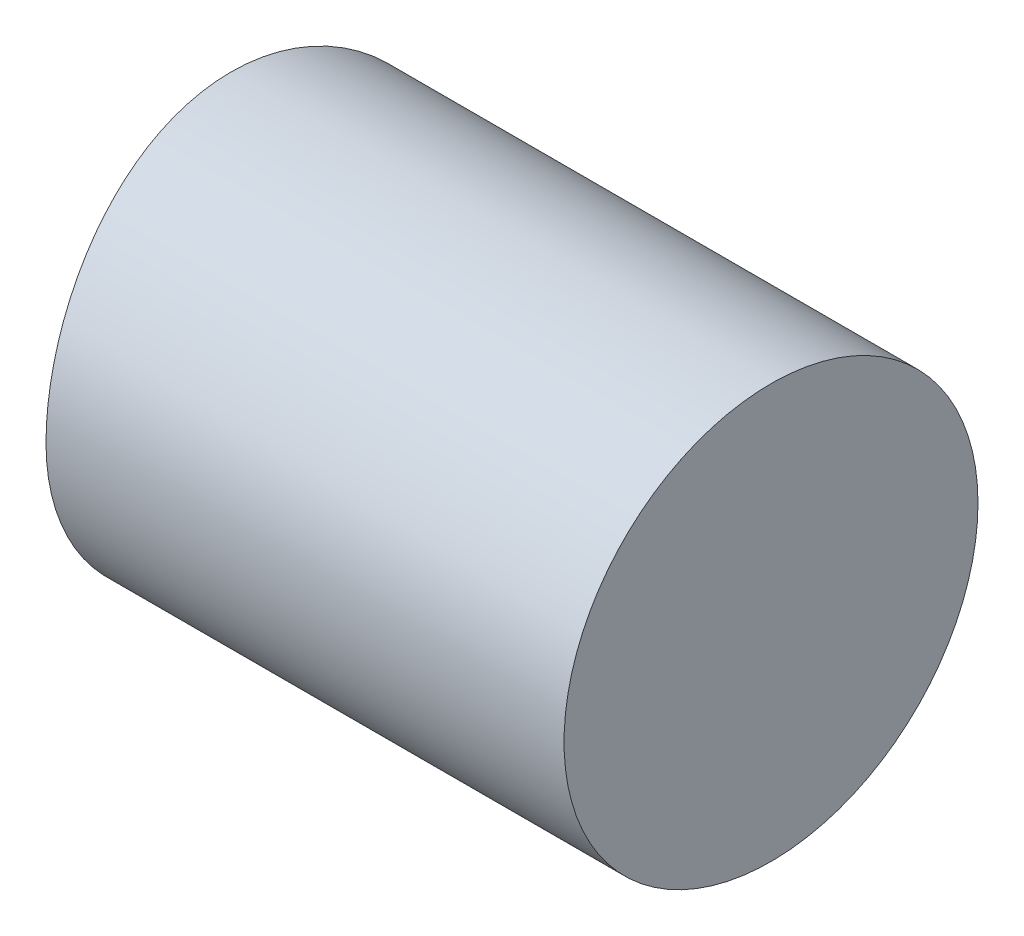
from build123d import *

# Parameters (mm, degrees)
SKETCH3_R                      = 2.921
BOSS_EXTRUDE2_DEPTH            = 7.62
CUT_EXTRUDE1_REACH             = 4.921
CUT_EXTRUDE1_DIRECTION_2_REACH = 4.921
CUT_EXTRUDE2_REACH             = 4.921
SKETCH5_W                      = 1.524
SKETCH5_H                      = 0.762
CUT_EXTRUDE2_DIRECTION_2_REACH = 4.921


with BuildPart() as part:
    # Sketch3 → Boss-Extrude2 (new body)
    with BuildSketch(Plane(origin=(0, 0, 0), x_dir=(0, 0, -1), z_dir=(1, 0, 0))):
        Circle(SKETCH3_R)
    extrude(amount=BOSS_EXTRUDE2_DEPTH)

    # Sketch4 → Cut-Extrude1 (cut, up to next)
    with BuildSketch(Plane.XY, mode=Mode.PRIVATE) as cut_extrude1_sk1:
        with BuildLine():
            Line((0.308789988, 0), (0.308789988, -2.921))
            Line((0.308789988, -2.921), (0, -2.921))
            Line((0, -2.921), (0, 2.921))
            ThreePointArc((0, 2.921), (0.231378009, 1.468638167), (0.308789988, 0))
        make_face()
    cut_extrude1_tool1 = extrude(cut_extrude1_sk1.sketch, amount=-CUT_EXTRUDE1_REACH, mode=Mode.PRIVATE) & part.part
    add(cut_extrude1_tool1.solids().sort_by_distance((0.142074, -0.436129, 0))[0], mode=Mode.SUBTRACT)

    # Sketch4 → Cut-Extrude1 direction 2 (cut, up to next)
    with BuildSketch(Plane.XY, mode=Mode.PRIVATE) as cut_extrude1_direction_2_sk1:
        with BuildLine():
            Line((0.308789988, 0), (0.308789988, -2.921))
            Line((0.308789988, -2.921), (0, -2.921))
            Line((0, -2.921), (0, 2.921))
            ThreePointArc((0, 2.921), (0.231378009, 1.468638167), (0.308789988, 0))
        make_face()
    cut_extrude1_direction_2_tool1 = extrude(cut_extrude1_direction_2_sk1.sketch, amount=CUT_EXTRUDE1_DIRECTION_2_REACH, mode=Mode.PRIVATE) & part.part
    add(cut_extrude1_direction_2_tool1.solids().sort_by_distance((0.142074, -0.436129, 0))[0], mode=Mode.SUBTRACT)

    # Sketch5 → Cut-Extrude2 (cut, up to next)
    with BuildSketch(Plane(origin=(0, 0, 0), x_dir=(1, 0, 0), z_dir=(0, 1, 0)), mode=Mode.PRIVATE) as cut_extrude2_sk1:
        with Locations((3.610789988, 2.54)):
            Rectangle(SKETCH5_W, SKETCH5_H)
    cut_extrude2_tool1 = extrude(cut_extrude2_sk1.sketch, amount=-CUT_EXTRUDE2_REACH, mode=Mode.PRIVATE) & part.part
    add(cut_extrude2_tool1.solids().sort_by_distance((3.61079, 0, -2.54))[0], mode=Mode.SUBTRACT)

    # Sketch5 → Cut-Extrude2 direction 2 (cut, up to next)
    with BuildSketch(Plane(origin=(0, 0, 0), x_dir=(1, 0, 0), z_dir=(0, 1, 0)), mode=Mode.PRIVATE) as cut_extrude2_direction_2_sk1:
        with Locations((3.610789988, 2.54)):
            Rectangle(SKETCH5_W, SKETCH5_H)
    cut_extrude2_direction_2_tool1 = extrude(cut_extrude2_direction_2_sk1.sketch, amount=CUT_EXTRUDE2_DIRECTION_2_REACH, mode=Mode.PRIVATE) & part.part
    add(cut_extrude2_direction_2_tool1.solids().sort_by_distance((3.61079, 0, -2.54))[0], mode=Mode.SUBTRACT)


solid = part.part
